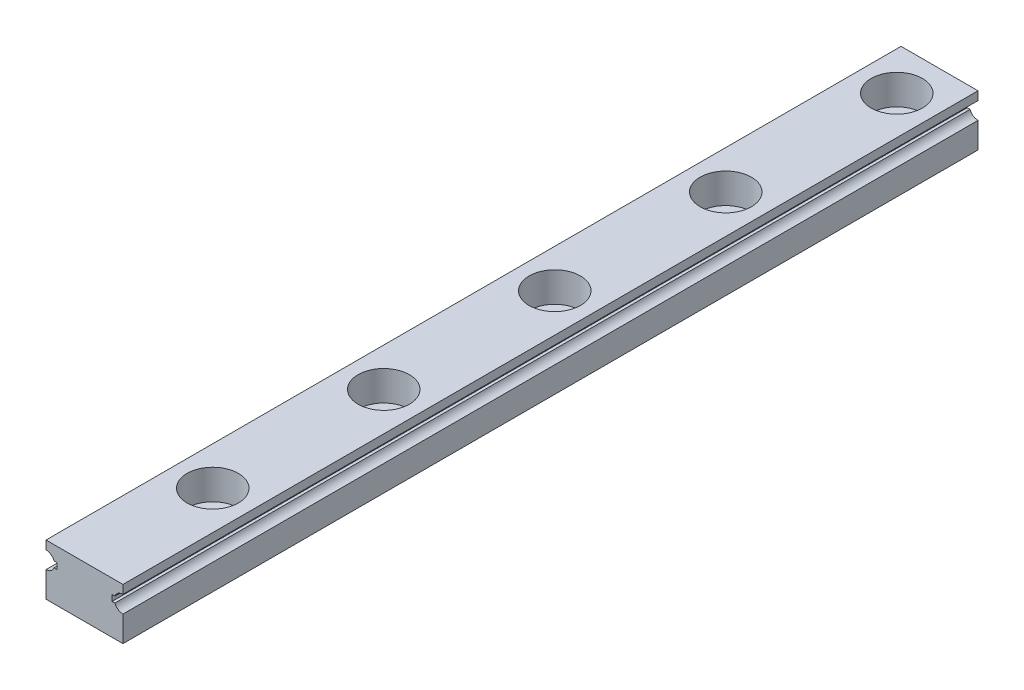
from build123d import *

# Parameters (mm, degrees)
EXTRUDE1_DEPTH  = 100
SKETCH2_R       = 3
EXTRUDE2_DEPTH  = 3.5
SKETCH_R        = 1.75
EXTRUDE3_DEPTH  = 101.280855601
LPATTERN1_COUNT = 30
LPATTERN1_PITCH = 20


with BuildPart() as part:
    # Sketch1 → Extrude1 (new body)
    with BuildSketch(Plane.XY):
        with BuildLine():
            Line((-4.5, -3), (4.5, -3))
            Line((4.5, -3), (4.5, 0))
            ThreePointArc((4.5, 0), (3.93077967, 0.177814974), (3.563991137, 0.648023568))
            Line((3.563991137, 0.648023568), (3.235073025, 0.648023568))
            Line((3.235073025, 0.648023568), (3.235073025, 1.351976432))
            Line((3.235073025, 1.351976432), (3.563991137, 1.351976432))
            ThreePointArc((3.563991137, 1.351976432), (3.93077967, 1.822185026), (4.5, 2))
            Line((4.5, 2), (4.5, 3))
            Line((4.5, 3), (-4.5, 3))
            Line((-4.5, 3), (-4.5, 2))
            ThreePointArc((-4.5, 2), (-3.93077967, 1.822185026), (-3.563991137, 1.351976432))
            Line((-3.563991137, 1.351976432), (-3.235073025, 1.351976432))
            Line((-3.235073025, 1.351976432), (-3.235073025, 0.648023568))
            Line((-3.235073025, 0.648023568), (-3.563991137, 0.648023568))
            ThreePointArc((-3.563991137, 0.648023568), (-3.93077967, 0.177814974), (-4.5, 0))
            Line((-4.5, 0), (-4.5, -3))
        make_face()
    extrude(amount=EXTRUDE1_DEPTH)

    # Sketch2 → Extrude2 (cut)
    with BuildSketch(Plane(origin=(0, 3, 0), x_dir=(1, 0, 0), z_dir=(0, 1, 0))):
        with Locations((0, -5)):
            Circle(SKETCH2_R)
    extrude2 = extrude(amount=-EXTRUDE2_DEPTH, mode=Mode.SUBTRACT)

    # Sketch → Extrude3 (cut, through all)
    with BuildSketch(Plane(origin=(0, 3, 0), x_dir=(1, 0, 0), z_dir=(0, 1, 0))):
        with Locations((0, -5)):
            Circle(SKETCH_R)
    extrude3 = extrude(amount=-EXTRUDE3_DEPTH, mode=Mode.SUBTRACT)

    # LPattern1: Extrude2, Extrude3 ×30
    with Locations(*[(0, 0, i * LPATTERN1_PITCH) for i in range(1, LPATTERN1_COUNT)]):
        add(extrude2, mode=Mode.SUBTRACT)
        add(extrude3, mode=Mode.SUBTRACT)


solid = part.part
